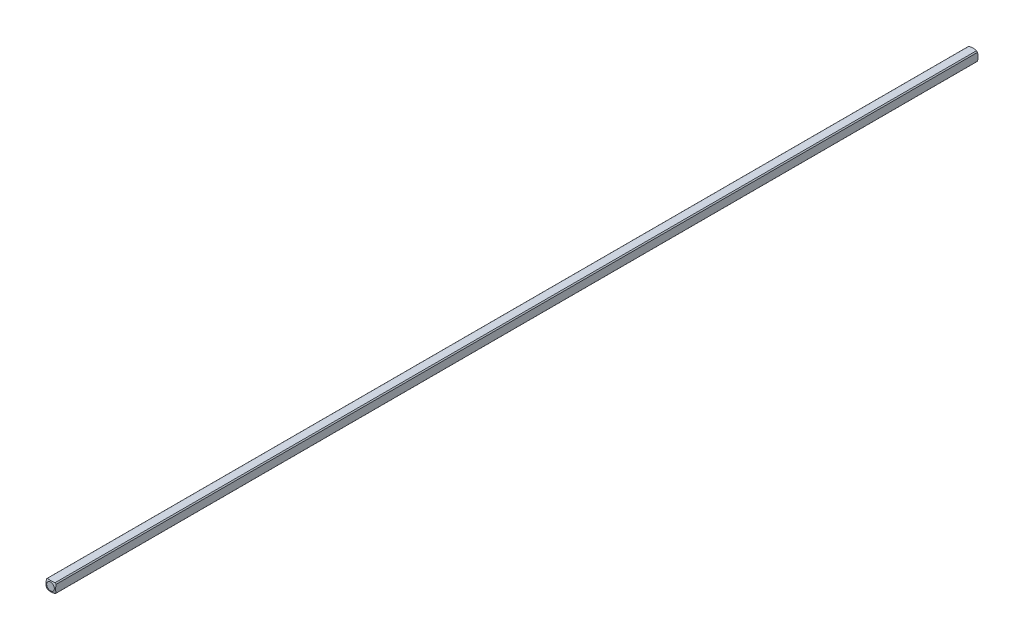
from build123d import *

# Parameters (mm, degrees)
SKETCH1_W           = 3.175
SKETCH1_H           = 3.175
BOSS_EXTRUDE1_DEPTH = 152.4
SKETCH2_OUTSIDE_W   = 35.668
SKETCH2_OUTSIDE_H   = 35.668
SKETCH2_OUTSIDE_R   = 2.032
CUT_EXTRUDE1_DEPTH  = 153.4


with BuildPart() as part:
    # Sketch1 → Boss-Extrude1 (new body)
    with BuildSketch(Plane.XY):
        Rectangle(SKETCH1_W, SKETCH1_H)
    extrude(amount=BOSS_EXTRUDE1_DEPTH)

    # Sketch2 outside → Cut-Extrude1 (cut, through all)
    with BuildSketch(Plane(origin=(0, 0, 0), x_dir=(-1, 0, 0), z_dir=(0, 0, -1))):
        Rectangle(SKETCH2_OUTSIDE_W, SKETCH2_OUTSIDE_H)
        Circle(SKETCH2_OUTSIDE_R, mode=Mode.SUBTRACT)
    extrude(amount=-CUT_EXTRUDE1_DEPTH, mode=Mode.SUBTRACT)

    # Sketch3 → Cut-Revolve1 (revolve, cut)
    with BuildSketch(Plane(origin=(0, 0, 0), x_dir=(1, 0, 0), z_dir=(0, 1, 0))):
        with BuildLine():
            Line((-5.053685963, -4.40273269), (-5.053685963, 5.740530545))
            Line((-5.053685963, 5.740530545), (0, 5.740530545))
            Line((0, 5.740530545), (0, 0.160877736))
            ThreePointArc((0, 0.160877736), (-3.404639553, -1.148866368), (-5.053685963, -4.40273269))
        make_face()
    revolve(axis=Axis((0, 0, 152.4), (0, 0, -1)), mode=Mode.SUBTRACT)

    # Mirror1: part across plane


with BuildPart() as part_1:
    add(part.part)
    add(part.part.mirror(Plane(origin=(0, 0, 152.4), x_dir=(1, 0, 0), z_dir=(0, 0, -1))))


solid = part_1.part
